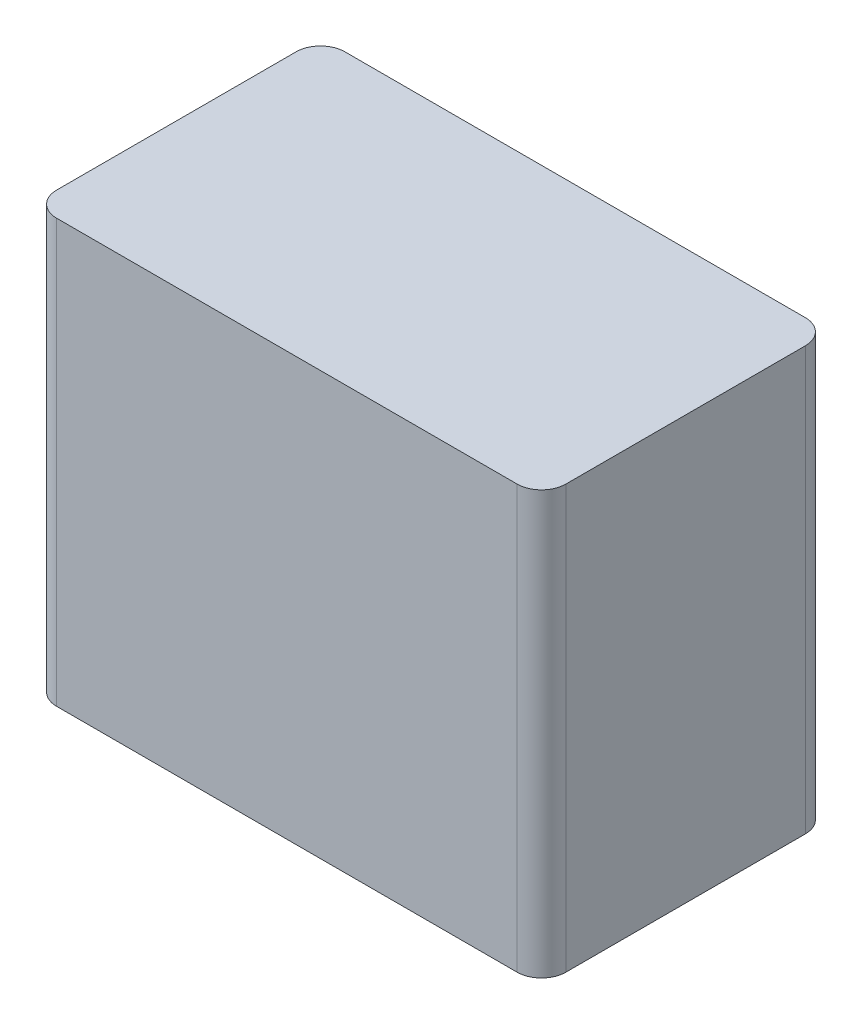
from build123d import *

# Parameters (mm, degrees)
SKETCH1_W           = 53
SKETCH1_H           = 44
BOSS_EXTRUDE1_DEPTH = 30
FILLET1_R           = 2.54


with BuildPart() as part:
    # Sketch1 → Boss-Extrude1 (new body)
    with BuildSketch(Plane.XY):
        with Locations((-26.5, 22)):
            Rectangle(SKETCH1_W, SKETCH1_H)
    extrude(amount=BOSS_EXTRUDE1_DEPTH)

    # Fillet1
    fillet1_edges = [part.edges().sort_by_distance(p)[0] for p in [
        (-53, 22, 30),
        (0, 22, 30),
        (-53, 22, 0),
        (0, 22, 0),
    ]]
    fillet(fillet1_edges, radius=FILLET1_R)


solid = part.part
